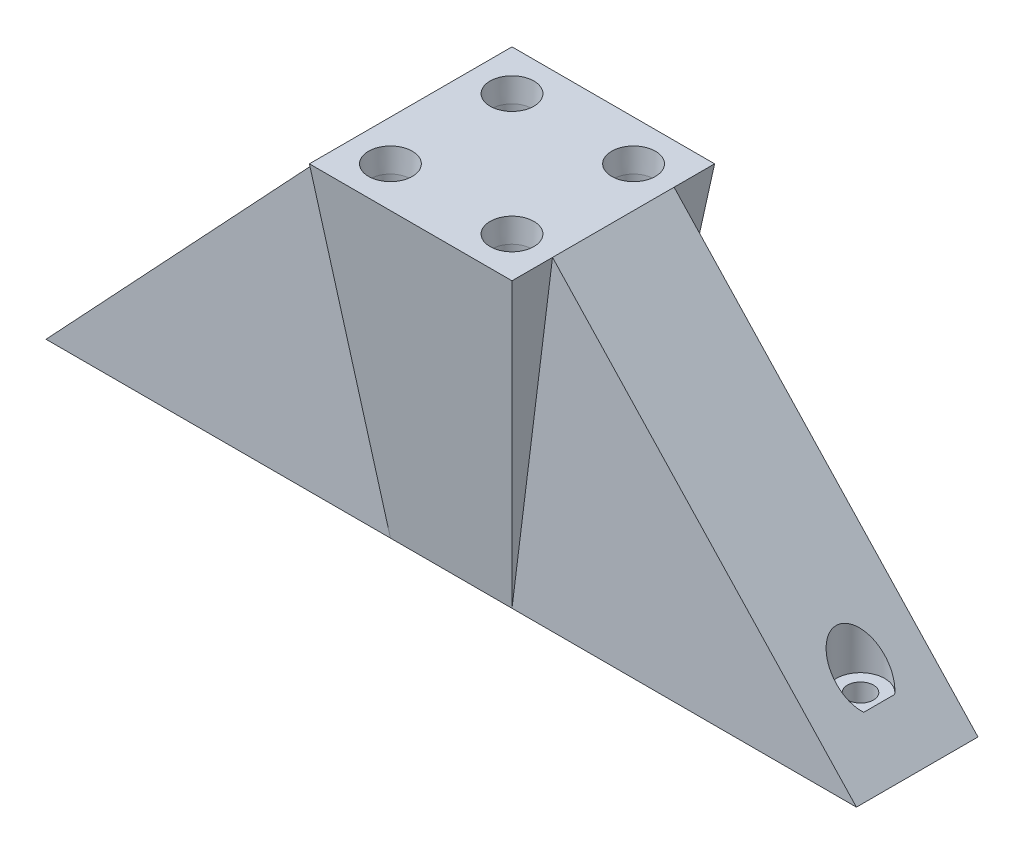
from build123d import *

# Parameters (mm, degrees)
SKETCH2_W            = 15
SKETCH2_H            = 15
BOSS_EXTRUDE1_DEPTH  = 40
BOSS_EXTRUDE1_TAPER  = -7.125
SKETCH2_4_W          = 42.5
SKETCH2_4_H          = 15
BOSS_EXTRUDE4_DEPTH  = 40
CUT_EXTRUDE1_DEPTH   = 15
CUT_EXTRUDE2_START   = -5
SKETCH5_R            = 1.6
SKETCH5_R_2          = 3
CUT_EXTRUDE2_DEPTH   = 35
SKETCH5_3_R          = 1.6
CUT_EXTRUDE3_DEPTH   = 41.0000001
LPATTERN1_COUNT      = 2
LPATTERN1_PITCH      = 15
LPATTERN1_COUNT_DIR2 = 2
LPATTERN1_PITCH_DIR2 = 15


with BuildPart() as part:
    # Sketch2 → Boss-Extrude1 (new body)
    with BuildSketch(Plane(origin=(0, 0, 0), x_dir=(1, 0, 0), z_dir=(0, 1, 0))):
        Rectangle(SKETCH2_W, SKETCH2_H)
    extrude(amount=BOSS_EXTRUDE1_DEPTH, taper=BOSS_EXTRUDE1_TAPER)

    # Sketch2_4 → Boss-Extrude4 (add)
    with BuildSketch(Plane(origin=(0, 0, 0), x_dir=(1, 0, 0), z_dir=(0, 1, 0))):
        with Locations((-28.75, 0)):
            Rectangle(SKETCH2_4_W, SKETCH2_4_H)
        with Locations((28.75, 0)):
            Rectangle(SKETCH2_4_W, SKETCH2_4_H)
    extrude(amount=BOSS_EXTRUDE4_DEPTH)

    # Sketch4 → Cut-Extrude1 (cut)
    with BuildSketch(Plane(origin=(0, 0, -7.5), x_dir=(-1, 0, 0), z_dir=(0, 0, -1))):
        Polygon((-12.499988408, 40), (-50, 0), (-50, 40), align=None)
    cut_extrude1 = extrude(amount=-CUT_EXTRUDE1_DEPTH, mode=Mode.SUBTRACT)

    # Sketch5 → Cut-Extrude2 (cut)
    with BuildSketch(Plane.XZ.offset(CUT_EXTRUDE2_START)):
        with Locations((43, 0)):
            Circle(SKETCH5_R)
        with Locations((43, 0)):
            Circle(SKETCH5_R_2)
        with Locations((43, 0)):
            Circle(SKETCH5_R, mode=Mode.SUBTRACT)
    cut_extrude2 = extrude(amount=-CUT_EXTRUDE2_DEPTH, mode=Mode.SUBTRACT)

    # Sketch5_3 → Cut-Extrude3 (cut, through all)
    with BuildSketch(Plane.XZ):
        with Locations((43, 0)):
            Circle(SKETCH5_3_R)
    cut_extrude3 = extrude(amount=-CUT_EXTRUDE3_DEPTH, mode=Mode.SUBTRACT)

    # Mirror1: Cut-Extrude1, Cut-Extrude2, Cut-Extrude3 across plane
    add(cut_extrude1.mirror(Plane(origin=(0, 0, 0), x_dir=(0, 0, 1), z_dir=(1, 0, 0))), mode=Mode.SUBTRACT)
    add(cut_extrude2.mirror(Plane(origin=(0, 0, 0), x_dir=(0, 0, 1), z_dir=(1, 0, 0))), mode=Mode.SUBTRACT)
    add(cut_extrude3.mirror(Plane(origin=(0, 0, 0), x_dir=(0, 0, 1), z_dir=(1, 0, 0))), mode=Mode.SUBTRACT)

    # Sketch8 → CSK for M3 Oval Head Machine Screw1 (revolve, cut)
    with BuildSketch(Plane(origin=(-7.499988408, 40, -7.499988408), x_dir=(0, 0, 1), z_dir=(1, 0, 0))):
        Polygon((0, 0), (0, 11.502151548), (2.5, 10), (2.5, 2.860133251), (2.7, 0), align=None)
    csk_for_m3_oval_head_machine_screw1 = revolve(axis=Axis((-7.499988408, 46.35, -7.499988408), (0, -1, 0)), mode=Mode.SUBTRACT)

    # LPattern1: CSK for M3 Oval Head Machine Screw1 2 × 2
    with Locations(*[(j * LPATTERN1_PITCH_DIR2, 0, i * LPATTERN1_PITCH) for i in range(LPATTERN1_COUNT) for j in range(LPATTERN1_COUNT_DIR2) if (i, j) != (0, 0)]):
        add(csk_for_m3_oval_head_machine_screw1, mode=Mode.SUBTRACT)


solid = part.part
